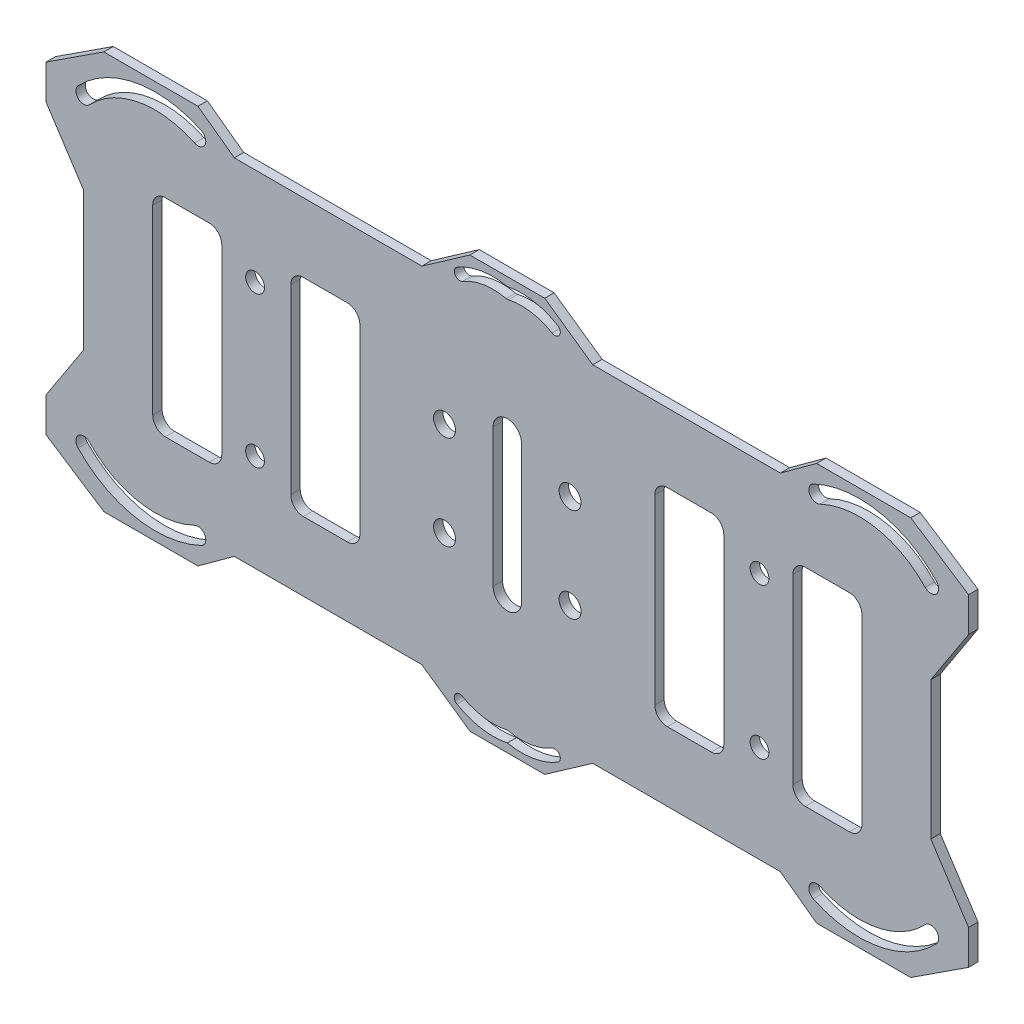
from build123d import *

# Parameters (mm, degrees)
SCHIZZO1_R                   = 1.5
ESTRUSIONE_ESTRUSIONE1_DEPTH = 0.75
SKETCH1_R                    = 1.75
CUT_EXTRUDE1_DEPTH           = 1
CUT_EXTRUDE1_DEPTH_BACK      = 2.5


with BuildPart() as part:
    # Schizzo1 → Estrusione-Estrusione1 (new body, symmetric)
    with BuildSketch(Plane.XY):
        Polygon((-43.5, -27.5), (-13.615232638, -27.5), (-5.964504028, -32.859521299), (5.964504028, -32.859521299), (13.615232638, -27.5), (43.5, -27.5), (49.293787181, -31.722358535), (64.293787181, -31.722358535), (73.508072858, -25.714285677), (73.508072858, -20.214285677), (67.5, -11), (67.5, 11), (73.508072858, 20.214285677), (73.508072858, 25.714285677), (64.293787181, 31.722358535), (49.293787181, 31.722358535), (43.5, 27.5), (13.615232638, 27.5), (5.964504028, 32.859521299), (-5.964504028, 32.859521299), (-13.615232638, 27.5), (-43.5, 27.5), (-49.293787181, 31.722358535), (-64.293787181, 31.722358535), (-73.508072858, 25.714285677), (-73.508072858, 20.214285677), (-67.5, 11), (-67.5, -11), (-73.508072858, -20.214285677), (-73.508072858, -25.714285677), (-64.293787181, -31.722358535), (-49.293787181, -31.722358535), align=None)
        with BuildLine():
            ThreePointArc((-48.754479002, -28.623738791), (-59.172775767, -30.009764998), (-68.405644393, -24.988200197))
            ThreePointArc((-68.405644393, -24.988200197), (-68.356417198, -23.226138607), (-66.594355607, -23.275365801))
            ThreePointArc((-66.594355607, -23.275365801), (-58.719274878, -27.558458065), (-49.83309536, -26.376261209))
            ThreePointArc((-49.83309536, -26.376261209), (-48.17004839, -26.960691821), (-48.754479002, -28.623738791))
        make_face(mode=Mode.SUBTRACT)
        with Locations((-40.191447808, -12)):
            Circle(SCHIZZO1_R, mode=Mode.SUBTRACT)
        with BuildLine():
            ThreePointArc((0, -31.496185519), (-4.133745369, -31.563971562), (-8.018095478, -30.148249145))
            ThreePointArc((-8.018095478, -30.148249145), (-8.326872952, -28.953648185), (-7.132271992, -28.644870711))
            ThreePointArc((-7.132271992, -28.644870711), (-3.764579281, -29.856257566), (-0.187146253, -29.75240554))
            ThreePointArc((-0.187146253, -29.75240554), (0, -29.732097651), (0.187146253, -29.75240554))
            ThreePointArc((0.187146253, -29.75240554), (3.764579281, -29.856257566), (7.132271992, -28.644870711))
            ThreePointArc((7.132271992, -28.644870711), (8.326872952, -28.953648185), (8.018095478, -30.148249145))
            ThreePointArc((8.018095478, -30.148249145), (4.133745369, -31.563971562), (0, -31.496185519))
        make_face(mode=Mode.SUBTRACT)
        with BuildLine():
            ThreePointArc((66.594355607, -23.275365801), (68.356417198, -23.226138607), (68.405644393, -24.988200197))
            ThreePointArc((68.405644393, -24.988200197), (59.172775767, -30.009764998), (48.754479002, -28.623738791))
            ThreePointArc((48.754479002, -28.623738791), (48.17004839, -26.960691821), (49.83309536, -26.376261209))
            ThreePointArc((49.83309536, -26.376261209), (58.719274878, -27.558458065), (66.594355607, -23.275365801))
        make_face(mode=Mode.SUBTRACT)
        with Locations((40.191447808, -12)):
            Circle(SCHIZZO1_R, mode=Mode.SUBTRACT)
        with BuildLine():
            Line((-47.5, -16.5), (-54.5, -16.5))
            ThreePointArc((-54.5, -16.5), (-55.914213562, -15.914213562), (-56.5, -14.5))
            Line((-56.5, -14.5), (-56.5, 14.5))
            ThreePointArc((-56.5, 14.5), (-55.914213562, 15.914213562), (-54.5, 16.5))
            Line((-54.5, 16.5), (-47.5, 16.5))
            ThreePointArc((-47.5, 16.5), (-46.085786438, 15.914213562), (-45.5, 14.5))
            Line((-45.5, 14.5), (-45.5, -14.5))
            ThreePointArc((-45.5, -14.5), (-46.085786438, -15.914213562), (-47.5, -16.5))
        make_face(mode=Mode.SUBTRACT)
        with Locations((-40.191447808, 12)):
            Circle(SCHIZZO1_R, mode=Mode.SUBTRACT)
        with BuildLine():
            Line((-25.5, -16.5), (-32.5, -16.5))
            ThreePointArc((-32.5, -16.5), (-33.914213562, -15.914213562), (-34.5, -14.5))
            Line((-34.5, -14.5), (-34.5, 14.5))
            ThreePointArc((-34.5, 14.5), (-33.914213562, 15.914213562), (-32.5, 16.5))
            Line((-32.5, 16.5), (-25.5, 16.5))
            ThreePointArc((-25.5, 16.5), (-24.085786438, 15.914213562), (-23.5, 14.5))
            Line((-23.5, 14.5), (-23.5, -14.5))
            ThreePointArc((-23.5, -14.5), (-24.085786438, -15.914213562), (-25.5, -16.5))
        make_face(mode=Mode.SUBTRACT)
        with BuildLine():
            ThreePointArc((-2.261398956, 11), (0, 13.261398956), (2.261398956, 11))
            Line((2.261398956, 11), (2.261398956, -11))
            ThreePointArc((2.261398956, -11), (0, -13.261398956), (-2.261398956, -11))
            Line((-2.261398956, -11), (-2.261398956, 11))
        make_face(mode=Mode.SUBTRACT)
        with BuildLine():
            ThreePointArc((-66.594355607, 23.275365801), (-68.356417198, 23.226138607), (-68.405644393, 24.988200197))
            ThreePointArc((-68.405644393, 24.988200197), (-67.961138694, 25.440973547), (-67.5, 25.876794757))
            ThreePointArc((-67.5, 25.876794757), (-58.546813094, 30.113494239), (-48.754479002, 28.623738791))
            ThreePointArc((-48.754479002, 28.623738791), (-48.17004839, 26.960691821), (-49.83309536, 26.376261209))
            ThreePointArc((-49.83309536, 26.376261209), (-58.719274878, 27.558458065), (-66.594355607, 23.275365801))
        make_face(mode=Mode.SUBTRACT)
        with BuildLine():
            ThreePointArc((25.5, -16.5), (24.085786438, -15.914213562), (23.5, -14.5))
            Line((23.5, -14.5), (23.5, 14.5))
            ThreePointArc((23.5, 14.5), (24.085786438, 15.914213562), (25.5, 16.5))
            Line((25.5, 16.5), (32.5, 16.5))
            ThreePointArc((32.5, 16.5), (33.914213562, 15.914213562), (34.5, 14.5))
            Line((34.5, 14.5), (34.5, -14.5))
            ThreePointArc((34.5, -14.5), (33.914213562, -15.914213562), (32.5, -16.5))
            Line((32.5, -16.5), (25.5, -16.5))
        make_face(mode=Mode.SUBTRACT)
        with BuildLine():
            ThreePointArc((47.5, -16.5), (46.085786438, -15.914213562), (45.5, -14.5))
            Line((45.5, -14.5), (45.5, 14.5))
            ThreePointArc((45.5, 14.5), (46.085786438, 15.914213562), (47.5, 16.5))
            Line((47.5, 16.5), (54.5, 16.5))
            ThreePointArc((54.5, 16.5), (55.914213562, 15.914213562), (56.5, 14.5))
            Line((56.5, 14.5), (56.5, -14.5))
            ThreePointArc((56.5, -14.5), (55.914213562, -15.914213562), (54.5, -16.5))
            Line((54.5, -16.5), (47.5, -16.5))
        make_face(mode=Mode.SUBTRACT)
        with Locations((40.191447808, 12)):
            Circle(SCHIZZO1_R, mode=Mode.SUBTRACT)
        with BuildLine():
            ThreePointArc((0.187146253, 29.75240554), (0, 29.732097651), (-0.187146253, 29.75240554))
            ThreePointArc((-0.187146253, 29.75240554), (-3.764579281, 29.856257566), (-7.132271992, 28.644870711))
            ThreePointArc((-7.132271992, 28.644870711), (-8.326872952, 28.953648185), (-8.018095478, 30.148249145))
            ThreePointArc((-8.018095478, 30.148249145), (-4.133745369, 31.563971562), (0, 31.496185519))
            ThreePointArc((0, 31.496185519), (4.133745369, 31.563971562), (8.018095478, 30.148249145))
            ThreePointArc((8.018095478, 30.148249145), (8.326872952, 28.953648185), (7.132271992, 28.644870711))
            ThreePointArc((7.132271992, 28.644870711), (3.764579281, 29.856257566), (0.187146253, 29.75240554))
        make_face(mode=Mode.SUBTRACT)
        with BuildLine():
            ThreePointArc((48.754479002, 28.623738791), (59.172775767, 30.009764998), (68.405644393, 24.988200197))
            ThreePointArc((68.405644393, 24.988200197), (68.356417198, 23.226138607), (66.594355607, 23.275365801))
            ThreePointArc((66.594355607, 23.275365801), (58.719274878, 27.558458065), (49.83309536, 26.376261209))
            ThreePointArc((49.83309536, 26.376261209), (48.17004839, 26.960691821), (48.754479002, 28.623738791))
        make_face(mode=Mode.SUBTRACT)
    extrude(amount=ESTRUSIONE_ESTRUSIONE1_DEPTH, both=True)

    # Sketch1 → Cut-Extrude1 (cut, two sides)
    with BuildSketch(Plane(origin=(0, 0, -0.75), x_dir=(-1, 0, 0), z_dir=(0, 0, -1))) as cut_extrude1_sk:
        with Locations((-10, 7.5)):
            Circle(SKETCH1_R)
        with Locations((-10, -7.5)):
            Circle(SKETCH1_R)
        with Locations((10, -7.5)):
            Circle(SKETCH1_R)
        with Locations((10, 7.5)):
            Circle(SKETCH1_R)
    extrude(amount=CUT_EXTRUDE1_DEPTH, mode=Mode.SUBTRACT)
    extrude(cut_extrude1_sk.sketch, amount=-CUT_EXTRUDE1_DEPTH_BACK, mode=Mode.SUBTRACT)


solid = part.part
